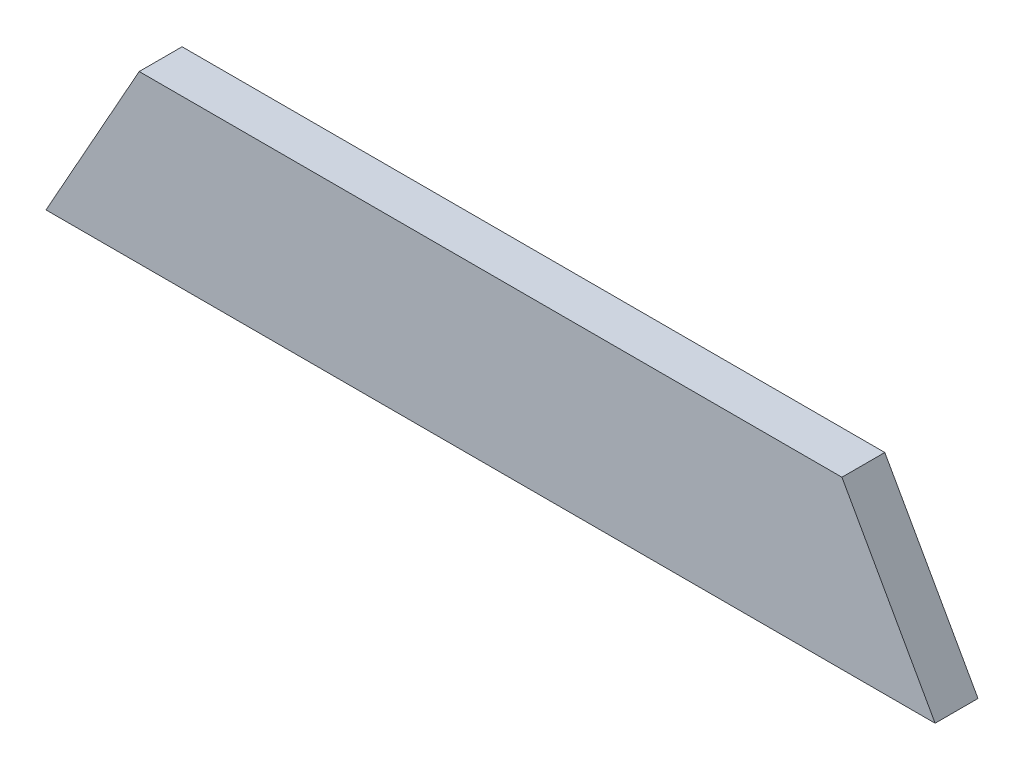
from build123d import *

# Parameters (mm, degrees)
BOSS_EXTRUDE1_DEPTH = 4.6


with BuildPart() as part:
    # Sketch1 → Boss-Extrude1 (new body)
    with BuildSketch(Plane.XY):
        Polygon((0, 0), (75.4, 0), (85.4, -17.861156178), (-10, -17.861156178), align=None)
    extrude(amount=BOSS_EXTRUDE1_DEPTH)


solid = part.part
